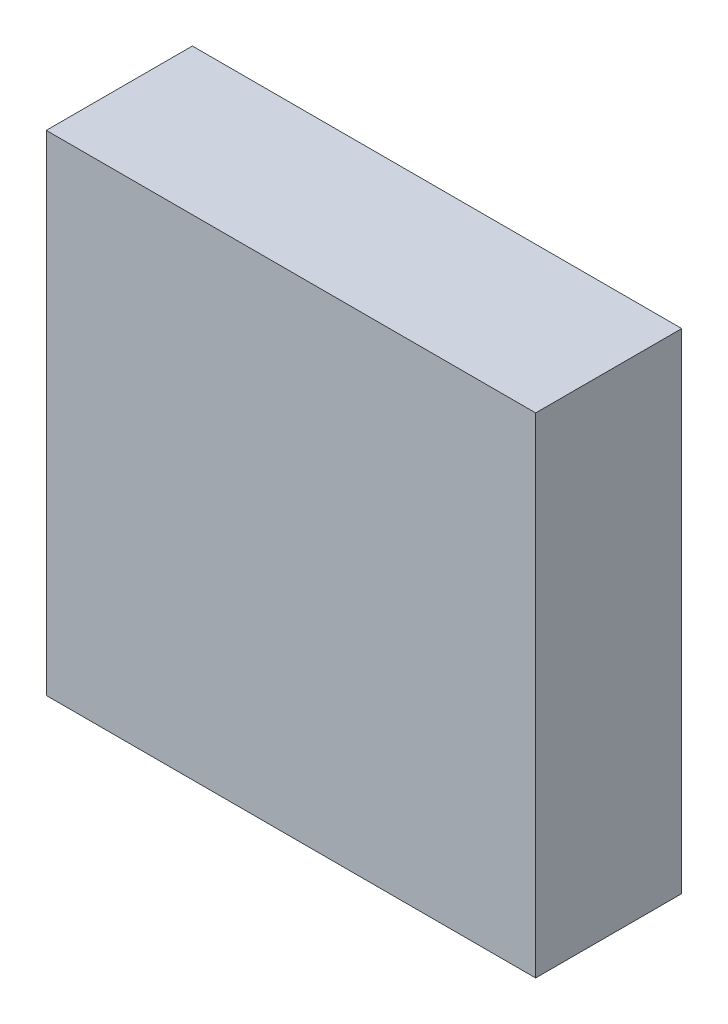
from build123d import *

# Parameters (mm, degrees)
SCHIZZO1_W                   = 41.2
SCHIZZO1_H                   = 41.2
ESTRUSIONE_ESTRUSIONE1_DEPTH = 12.3
SCHIZZO2_W                   = 6.6
SCHIZZO2_H                   = 3.5
TAGLIO_ESTRUSIONE1_DEPTH     = 42
SCHIZZO3_W                   = 6.6
SCHIZZO3_H                   = 2.261378951
ESTRUSIONE_ESTRUSIONE2_DEPTH = 5


with BuildPart() as part:
    # Schizzo1 → Estrusione-Estrusione1 (new body)
    with BuildSketch(Plane.XY):
        with Locations((20.6, 20.6)):
            Rectangle(SCHIZZO1_W, SCHIZZO1_H)
    extrude(amount=ESTRUSIONE_ESTRUSIONE1_DEPTH)

    # Schizzo2 → Taglio-Estrusione1 (cut)
    with BuildSketch(Plane(origin=(0, 41.2, 0), x_dir=(1, 0, 0), z_dir=(0, 1, 0))):
        with Locations((5.5, -3.35)):
            Rectangle(SCHIZZO2_W, SCHIZZO2_H)
    extrude(amount=-TAGLIO_ESTRUSIONE1_DEPTH, mode=Mode.SUBTRACT)

    # Schizzo3 → Estrusione-Estrusione2 (add)
    with BuildSketch(Plane(origin=(0, 0, 5.1), x_dir=(-1, 0, 0), z_dir=(0, 0, -1))):
        with Locations((-5.5, 40.069310525)):
            Rectangle(SCHIZZO3_W, SCHIZZO3_H)
    extrude(amount=ESTRUSIONE_ESTRUSIONE2_DEPTH)


solid = part.part
